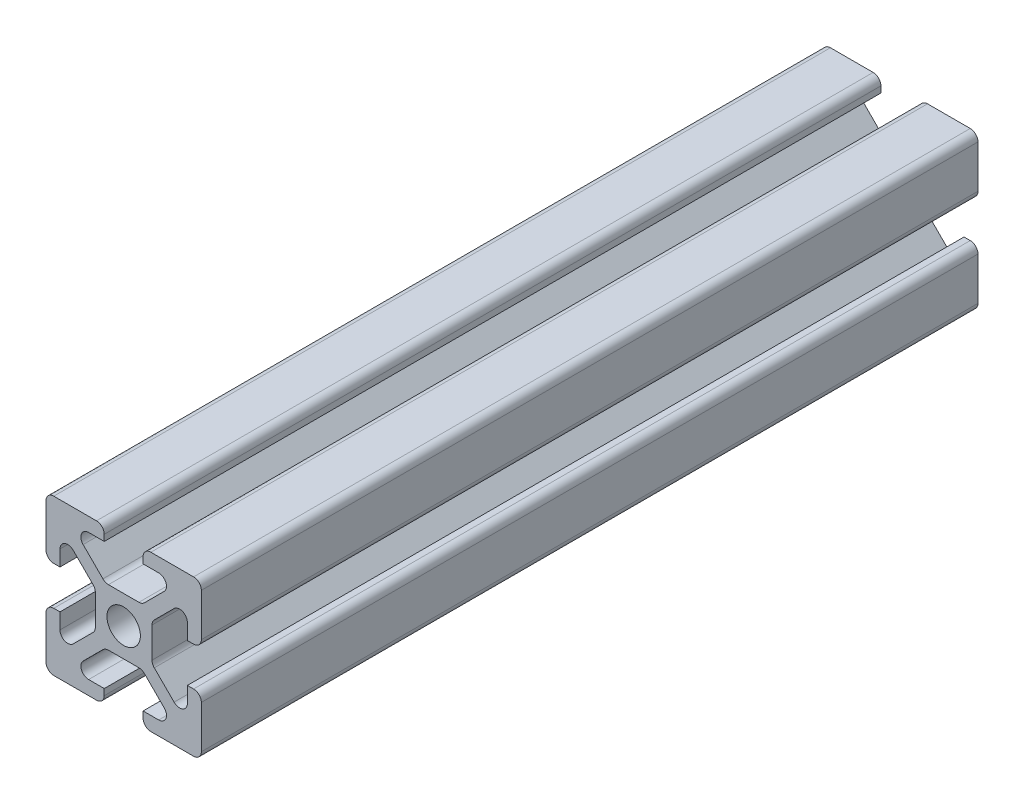
from build123d import *

# Parameters (mm, degrees)
SCHIZZO1_R                   = 2.15
ESTRUSIONE_ESTRUSIONE1_DEPTH = 100


with BuildPart() as part:
    # Schizzo1 → Estrusione-Estrusione1 (new body)
    with BuildSketch(Plane(origin=(0, 0, 0), x_dir=(-1, 0, 0), z_dir=(0, 0, -1))):
        with BuildLine():
            Line((8.2, 2.5), (9, 2.5))
            ThreePointArc((9, 2.5), (9.707106781, 2.792893219), (10, 3.5))
            Line((10, 3.5), (10, 9))
            ThreePointArc((10, 9), (9.707106781, 9.707106781), (9, 10))
            Line((9, 10), (3.5, 10))
            ThreePointArc((3.5, 10), (2.792893219, 9.707106781), (2.5, 9))
            Line((2.5, 9), (2.5, 8.2))
            Line((2.5, 8.2), (4.512994231, 8.2))
            ThreePointArc((4.512994231, 8.2), (5.436873764, 7.582683432), (5.220101013, 6.492893219))
            Line((5.220101013, 6.492893219), (2.670101013, 3.942893219))
            ThreePointArc((2.670101013, 3.942893219), (2.345677664, 3.726120467), (1.962994231, 3.65))
            Line((1.962994231, 3.65), (-1.962994231, 3.65))
            ThreePointArc((-1.962994231, 3.65), (-2.345677664, 3.726120467), (-2.670101013, 3.942893219))
            Line((-2.670101013, 3.942893219), (-5.220101013, 6.492893219))
            ThreePointArc((-5.220101013, 6.492893219), (-5.436873764, 7.582683432), (-4.512994231, 8.2))
            Line((-4.512994231, 8.2), (-2.5, 8.2))
            Line((-2.5, 8.2), (-2.5, 9))
            ThreePointArc((-2.5, 9), (-2.792893219, 9.707106781), (-3.5, 10))
            Line((-3.5, 10), (-9, 10))
            ThreePointArc((-9, 10), (-9.707106781, 9.707106781), (-10, 9))
            Line((-10, 9), (-10, 3.5))
            ThreePointArc((-10, 3.5), (-9.707106781, 2.792893219), (-9, 2.5))
            Line((-9, 2.5), (-8.2, 2.5))
            Line((-8.2, 2.5), (-8.2, 4.512994231))
            ThreePointArc((-8.2, 4.512994231), (-7.582683432, 5.436873764), (-6.492893219, 5.220101013))
            Line((-6.492893219, 5.220101013), (-3.942893219, 2.670101013))
            ThreePointArc((-3.942893219, 2.670101013), (-3.726120467, 2.345677664), (-3.65, 1.962994231))
            Line((-3.65, 1.962994231), (-3.65, -1.962994231))
            ThreePointArc((-3.65, -1.962994231), (-3.726120467, -2.345677664), (-3.942893219, -2.670101013))
            Line((-3.942893219, -2.670101013), (-6.492893219, -5.220101013))
            ThreePointArc((-6.492893219, -5.220101013), (-7.582683432, -5.436873764), (-8.2, -4.512994231))
            Line((-8.2, -4.512994231), (-8.2, -2.5))
            Line((-8.2, -2.5), (-9, -2.5))
            ThreePointArc((-9, -2.5), (-9.707106781, -2.792893219), (-10, -3.5))
            Line((-10, -3.5), (-10, -9))
            ThreePointArc((-10, -9), (-9.707106781, -9.707106781), (-9, -10))
            Line((-9, -10), (-3.5, -10))
            ThreePointArc((-3.5, -10), (-2.792893219, -9.707106781), (-2.5, -9))
            Line((-2.5, -9), (-2.5, -8.2))
            Line((-2.5, -8.2), (-4.512994231, -8.2))
            ThreePointArc((-4.512994231, -8.2), (-5.436873764, -7.582683432), (-5.220101013, -6.492893219))
            Line((-5.220101013, -6.492893219), (-2.670101013, -3.942893219))
            ThreePointArc((-2.670101013, -3.942893219), (-2.345677664, -3.726120467), (-1.962994231, -3.65))
            Line((-1.962994231, -3.65), (1.962994231, -3.65))
            ThreePointArc((1.962994231, -3.65), (2.345677664, -3.726120467), (2.670101013, -3.942893219))
            Line((2.670101013, -3.942893219), (5.220101013, -6.492893219))
            ThreePointArc((5.220101013, -6.492893219), (5.436873764, -7.582683432), (4.512994231, -8.2))
            Line((4.512994231, -8.2), (2.5, -8.2))
            Line((2.5, -8.2), (2.5, -9))
            ThreePointArc((2.5, -9), (2.792893219, -9.707106781), (3.5, -10))
            Line((3.5, -10), (9, -10))
            ThreePointArc((9, -10), (9.707106781, -9.707106781), (10, -9))
            Line((10, -9), (10, -3.5))
            ThreePointArc((10, -3.5), (9.707106781, -2.792893219), (9, -2.5))
            Line((9, -2.5), (8.2, -2.5))
            Line((8.2, -2.5), (8.2, -4.512994231))
            ThreePointArc((8.2, -4.512994231), (7.582683432, -5.436873764), (6.492893219, -5.220101013))
            Line((6.492893219, -5.220101013), (3.942893219, -2.670101013))
            ThreePointArc((3.942893219, -2.670101013), (3.726120467, -2.345677664), (3.65, -1.962994231))
            Line((3.65, -1.962994231), (3.65, 1.962994231))
            ThreePointArc((3.65, 1.962994231), (3.726120467, 2.345677664), (3.942893219, 2.670101013))
            Line((3.942893219, 2.670101013), (6.492893219, 5.220101013))
            ThreePointArc((6.492893219, 5.220101013), (7.582683432, 5.436873764), (8.2, 4.512994231))
            Line((8.2, 4.512994231), (8.2, 2.5))
        make_face()
        Circle(SCHIZZO1_R, mode=Mode.SUBTRACT)
    extrude(amount=-ESTRUSIONE_ESTRUSIONE1_DEPTH)


solid = part.part
